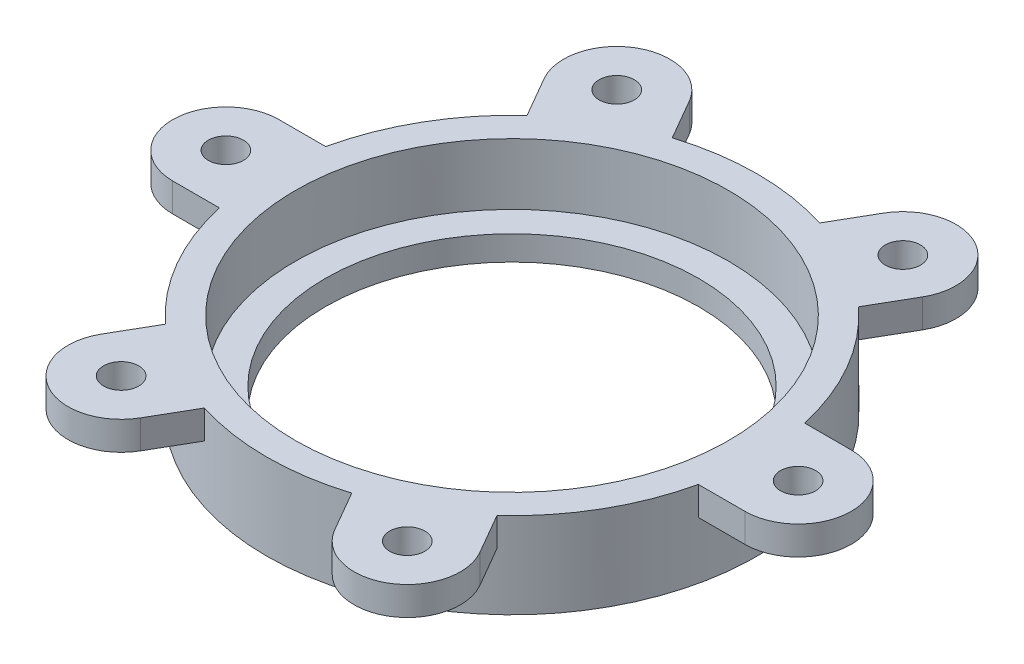
from build123d import *

# Parameters (mm, degrees)
SKETCH1_R           = 26
SKETCH1_R_2         = 2.15
BOSS_EXTRUDE1_DEPTH = 10.5
SKETCH2_R           = 27.448916739
SKETCH2_R_2         = 22.85
BOSS_EXTRUDE2_DEPTH = 3
SKETCH3_R           = 44.09476296
SKETCH3_R_2         = 30
CUT_EXTRUDE1_DEPTH  = 7
SKETCH4_R           = 26.5
CUT_EXTRUDE2_DEPTH  = 7.5


with BuildPart() as part:
    # Sketch1 → Boss-Extrude1 (new body)
    with BuildSketch(Plane(origin=(0, 0, 0), x_dir=(1, 0, 0), z_dir=(0, 1, 0))):
        with BuildLine():
            Line((11.870834875, -33.560889132), (9.014519521, -28.613605816))
            ThreePointArc((9.014519521, -28.613605816), (0, -30), (-9.014519521, -28.613605816))
            Line((-9.014519521, -28.613605816), (-11.870834875, -33.560889132))
            ThreePointArc((-11.870834875, -33.560889132), (-20.75, -35.940054257), (-23.129165125, -27.060889132))
            Line((-23.129165125, -27.060889132), (-20.27284977, -22.113605816))
            ThreePointArc((-20.27284977, -22.113605816), (-25.980762114, -15), (-29.287369291, -6.5))
            Line((-29.287369291, -6.5), (-35, -6.5))
            ThreePointArc((-35, -6.5), (-41.5, 0), (-35, 6.5))
            Line((-35, 6.5), (-29.287369291, 6.5))
            ThreePointArc((-29.287369291, 6.5), (-25.980762114, 15), (-20.27284977, 22.113605816))
            Line((-20.27284977, 22.113605816), (-23.129165125, 27.060889132))
            ThreePointArc((-23.129165125, 27.060889132), (-20.75, 35.940054257), (-11.870834875, 33.560889132))
            Line((-11.870834875, 33.560889132), (-9.014519521, 28.613605816))
            ThreePointArc((-9.014519521, 28.613605816), (0, 30), (9.014519521, 28.613605816))
            Line((9.014519521, 28.613605816), (11.870834875, 33.560889132))
            ThreePointArc((11.870834875, 33.560889132), (20.75, 35.940054257), (23.129165125, 27.060889132))
            Line((23.129165125, 27.060889132), (20.27284977, 22.113605816))
            ThreePointArc((20.27284977, 22.113605816), (25.980762114, 15), (29.287369291, 6.5))
            Line((29.287369291, 6.5), (35, 6.5))
            ThreePointArc((35, 6.5), (41.5, 0), (35, -6.5))
            Line((35, -6.5), (29.287369291, -6.5))
            ThreePointArc((29.287369291, -6.5), (25.980762114, -15), (20.27284977, -22.113605816))
            Line((20.27284977, -22.113605816), (23.129165125, -27.060889132))
            ThreePointArc((23.129165125, -27.060889132), (20.75, -35.940054257), (11.870834875, -33.560889132))
        make_face()
        Circle(SKETCH1_R, mode=Mode.SUBTRACT)
        with Locations((35, 0)):
            Circle(SKETCH1_R_2, mode=Mode.SUBTRACT)
        with Locations((17.5, -30.310889132)):
            Circle(SKETCH1_R_2, mode=Mode.SUBTRACT)
        with Locations((-17.5, -30.310889132)):
            Circle(SKETCH1_R_2, mode=Mode.SUBTRACT)
        with Locations((-35, 0)):
            Circle(SKETCH1_R_2, mode=Mode.SUBTRACT)
        with Locations((-17.5, 30.310889132)):
            Circle(SKETCH1_R_2, mode=Mode.SUBTRACT)
        with Locations((17.5, 30.310889132)):
            Circle(SKETCH1_R_2, mode=Mode.SUBTRACT)
    extrude(amount=BOSS_EXTRUDE1_DEPTH)

    # Sketch2 → Boss-Extrude2 (add)
    with BuildSketch(Plane.XZ):
        Circle(SKETCH2_R)
        Circle(SKETCH2_R_2, mode=Mode.SUBTRACT)
    extrude(amount=-BOSS_EXTRUDE2_DEPTH)

    # Sketch3 → Cut-Extrude1 (cut)
    with BuildSketch(Plane.XZ):
        Circle(SKETCH3_R)
        Circle(SKETCH3_R_2, mode=Mode.SUBTRACT)
    extrude(amount=-CUT_EXTRUDE1_DEPTH, mode=Mode.SUBTRACT)

    # Sketch4 → Cut-Extrude2 (cut)
    with BuildSketch(Plane(origin=(0, 10.5, 0), x_dir=(1, 0, 0), z_dir=(0, 1, 0))):
        Circle(SKETCH4_R)
    extrude(amount=-CUT_EXTRUDE2_DEPTH, mode=Mode.SUBTRACT)


solid = part.part
